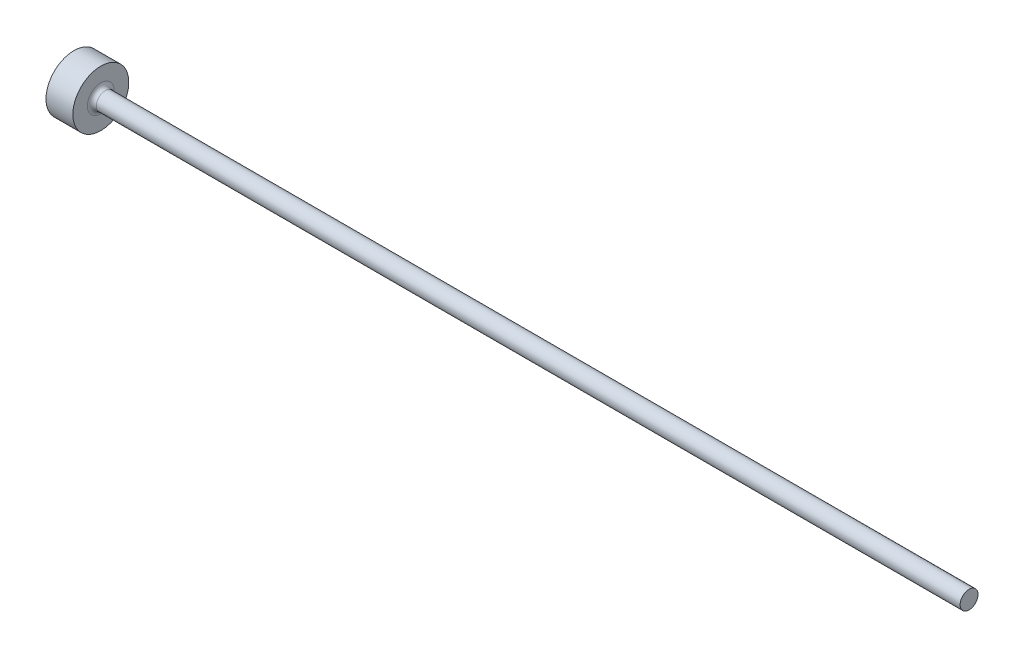
from build123d import *


with BuildPart() as part:
    # Skizze1 → Rotation1 (revolve)
    with BuildSketch(Plane.XY, mode=Mode.PRIVATE) as rotation1_sk:
        with BuildLine():
            Line((0, 0), (0, 1.25))
            Line((0, 1.25), (1.2, 1.25))
            Line((1.2, 1.25), (1.2, 0.6))
            ThreePointArc((1.2, 0.6), (1.258578644, 0.458578644), (1.4, 0.4))
            Line((1.4, 0.4), (40, 0.4))
            Line((40, 0.4), (40, 0))
            Line((40, 0), (0, 0))
        make_face()
    revolve(rotation1_sk.sketch.rotate(Axis((0, 0, 0), (1, 0, 0)), 90), axis=Axis((0, 0, 0), (1, 0, 0)))  # turned: the seam where the file's is


solid = part.part
